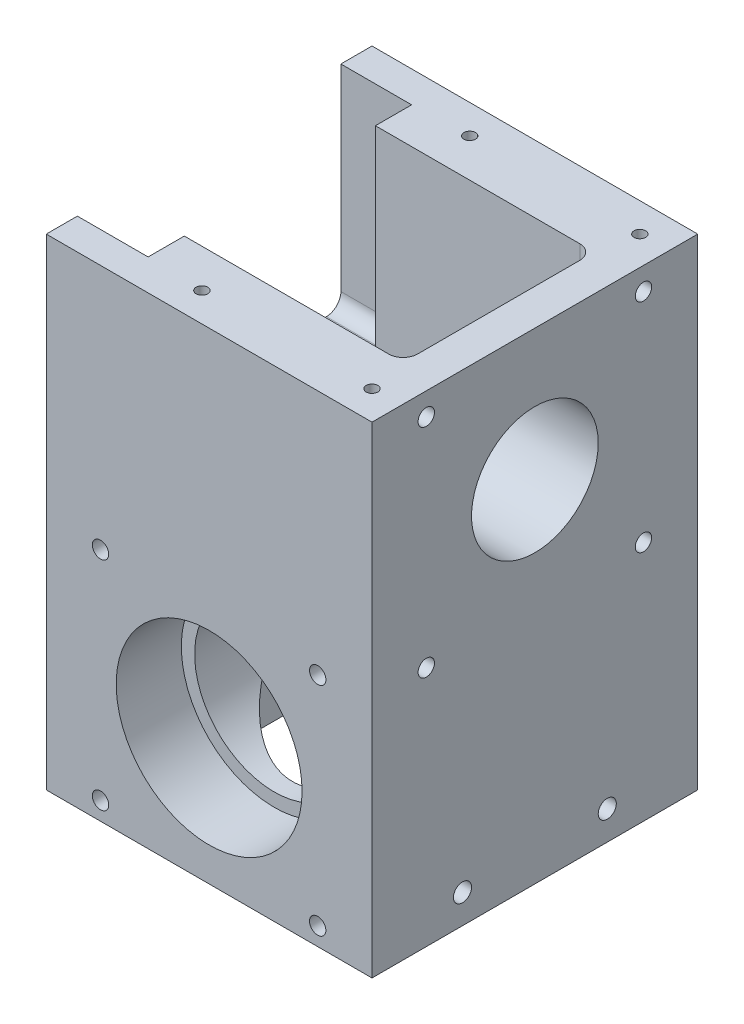
from build123d import *

# Parameters (mm, degrees)
SKETCH1_W                  = 45
SKETCH1_H                  = 45
BOSS_EXTRUDE1_DEPTH        = 30
BOSS_EXTRUDE1_DEPTH_BACK   = 35
F_22_0_22_DIAMETER_HOLE1_D = 22
F_22_0_22_DIAMETER_HOLE2_D = 22
SKETCH7_R                  = 12.8397
CUT_EXTRUDE1_DEPTH         = 9
CUT_EXTRUDE2_DEPTH         = 13.2
CUT_EXTRUDE3_REACH         = 29.667
SKETCH9_W                  = 26.4
SKETCH9_H                  = 36
FILLET1_R                  = 2
CUT_EXTRUDE6_REACH         = 29.667
CUT_EXTRUDE4_DEPTH         = 4.499464
CUT_EXTRUDE5_DEPTH         = 9.772078
CUT_EXTRUDE7_DEPTH         = 15
BOSS_EXTRUDE2_DEPTH        = 1.5
M2_TAPPED_HOLE1_D          = 1.6
M2_TAPPED_HOLE1_DEPTH      = 3.2
M2_TAPPED_HOLE1_TIP        = 0.480688495
M2_TAPPED_HOLE2_D          = 1.6
M2_TAPPED_HOLE2_DEPTH      = 5.2
M2_TAPPED_HOLE2_TIP        = 0.480688495
M2_TAPPED_HOLE3_D          = 1.6
M2_TAPPED_HOLE3_DEPTH      = 5.2
M2_TAPPED_HOLE3_TIP        = 0.480688495
M3_TAPPED_HOLE1_D          = 2.5
M3_TAPPED_HOLE2_D          = 2.5
M3_TAPPED_HOLE2_DEPTH      = 7.5
M3_TAPPED_HOLE2_TIP        = 0.751075774
M2_TAPPED_HOLE4_D          = 1.6
M2_TAPPED_HOLE4_DEPTH      = 5.2
M2_TAPPED_HOLE4_TIP        = 0.480688495
CUT_EXTRUDE8_REACH         = 47
SKETCH30_R                 = 8.75
F_4_40_TAPPED_HOLE1_D      = 2.2606
F_4_40_TAPPED_HOLE1_DEPTH  = 4.2
F_4_40_TAPPED_HOLE1_TIP    = 0.679152758
F_4_40_TAPPED_HOLE2_D      = 2.2606
F_4_40_TAPPED_HOLE2_DEPTH  = 5.18
F_4_40_TAPPED_HOLE2_TIP    = 0.679152758


with BuildPart() as part:
    # Sketch1 → Boss-Extrude1 (new body, two sides)
    with BuildSketch(Plane(origin=(0, 0, 0), x_dir=(1, 0, 0), z_dir=(0, 1, 0))) as boss_extrude1_sk:
        Rectangle(SKETCH1_W, SKETCH1_H)
    extrude(amount=BOSS_EXTRUDE1_DEPTH)
    extrude(boss_extrude1_sk.sketch, amount=-BOSS_EXTRUDE1_DEPTH_BACK)

    # Ø22.0 (22) Diameter Hole1 (through all)
    with Locations(Plane(origin=(0, 30, 0), x_dir=(1, 0, 0), z_dir=(0, 1, 0))):
        with Locations((0, 0)):
            Hole(F_22_0_22_DIAMETER_HOLE1_D / 2)

    # Ø22.0 (22) Diameter Hole2 (through all)
    with Locations(Plane.XY.offset(22.5)):
        with Locations((0, -17.5)):
            Hole(F_22_0_22_DIAMETER_HOLE2_D / 2)

    # Sketch7 → Cut-Extrude1 (cut)
    with BuildSketch(Plane.XY.offset(22.5)):
        with Locations((0, -17.5)):
            Circle(SKETCH7_R)
    extrude(amount=-CUT_EXTRUDE1_DEPTH, mode=Mode.SUBTRACT)

    # Sketch8 → Cut-Extrude2 (cut, symmetric)
    with BuildSketch(Plane.XY):
        Polygon((-12.727922061, 2.272077939), (-11.914749263, 1.45890514), (13.54109486, 26.914749263), (12.727922061, 27.727922061), align=None)
    extrude(amount=CUT_EXTRUDE2_DEPTH, both=True, mode=Mode.SUBTRACT)

    # Sketch9 → Cut-Extrude3 (cut, up to next)
    with BuildSketch(Plane(origin=(-6.686827202, 6.686827202, 0), x_dir=(0, 0, 1), z_dir=(-0.707106781, 0.707106781, 0)), mode=Mode.PRIVATE) as cut_extrude3_sk1:
        with Locations((0, 10.606601718)):
            Rectangle(SKETCH9_W, SKETCH9_H)
    cut_extrude3_tool1 = extrude(cut_extrude3_sk1.sketch, amount=CUT_EXTRUDE3_REACH, mode=Mode.PRIVATE) & part.part
    add(cut_extrude3_tool1.solids().sort_by_distance((0.813173, 14.186827, 0))[0], mode=Mode.SUBTRACT)

    # Fillet1
    fillet1_edges = [part.edges().sort_by_distance(p)[0] for p in [
        (11.998469491, 28.457374631, -13.2),
        (-17.207374631, 6.751530509, -13.2),
        (-17.207374631, 6.751530509, 13.2),
        (11.998469491, 28.457374631, 13.2),
    ]]
    fillet(fillet1_edges, radius=FILLET1_R)

    # Sketch12 → Cut-Extrude6 (cut, up to next)
    with BuildSketch(Plane(origin=(-6.686827202, 6.686827202, 0), x_dir=(0, 0, 1), z_dir=(-0.707106781, 0.707106781, 0)), mode=Mode.PRIVATE) as cut_extrude6_sk1:
        with BuildLine():
            Line((-9.2, -5.393398282), (-9.2, -7.393398282))
            ThreePointArc((-9.2, -7.393398282), (-11.2, -9.393398282), (-13.2, -7.393398282))
            Line((-13.2, -7.393398282), (-13.2, -5.393398282))
            ThreePointArc((-13.2, -5.393398282), (-11.2, -3.393398282), (-9.2, -5.393398282))
        make_face()
    cut_extrude6_tool1 = extrude(cut_extrude6_sk1.sketch, amount=CUT_EXTRUDE6_REACH, mode=Mode.PRIVATE) & part.part
    add(cut_extrude6_tool1.solids().sort_by_distance((-11.207642, 2.166012, -11.2))[0], mode=Mode.SUBTRACT)
    # Sketch12 → Cut-Extrude6 (cut, up to next)
    with BuildSketch(Plane(origin=(-6.686827202, 6.686827202, 0), x_dir=(0, 0, 1), z_dir=(-0.707106781, 0.707106781, 0)), mode=Mode.PRIVATE) as cut_extrude6_sk2:
        with BuildLine():
            Line((13.2, -5.393398282), (13.2, -7.393398282))
            ThreePointArc((13.2, -7.393398282), (11.2, -9.393398282), (9.2, -7.393398282))
            Line((9.2, -7.393398282), (9.2, -5.393398282))
            ThreePointArc((9.2, -5.393398282), (11.2, -3.393398282), (13.2, -5.393398282))
        make_face()
    cut_extrude6_tool2 = extrude(cut_extrude6_sk2.sketch, amount=CUT_EXTRUDE6_REACH, mode=Mode.PRIVATE) & part.part
    add(cut_extrude6_tool2.solids().sort_by_distance((-11.207642, 2.166012, 11.2))[0], mode=Mode.SUBTRACT)

    # Sketch10 → Cut-Extrude4 (cut)
    with BuildSketch(Plane(origin=(0, 30, 0), x_dir=(1, 0, 0), z_dir=(0, 1, 0))):
        with BuildLine():
            Line((7.627416998, 13.2), (15.5, 13.2))
            ThreePointArc((15.5, 13.2), (16.914213562, 12.614213562), (17.5, 11.2))
            Line((17.5, 11.2), (17.5, -11.2))
            ThreePointArc((17.5, -11.2), (16.914213562, -12.614213562), (15.5, -13.2))
            Line((15.5, -13.2), (7.627416998, -13.2))
            Line((7.627416998, -13.2), (7.627416998, 13.2))
        make_face()
    extrude(amount=-CUT_EXTRUDE4_DEPTH, mode=Mode.SUBTRACT)

    # Sketch11 → Cut-Extrude5 (cut)
    with BuildSketch(Plane.ZY.offset(22.5)):
        with BuildLine():
            Line((-18.2, 30), (18.2, 30))
            Line((18.2, 30), (18.2, 4.272077939))
            ThreePointArc((18.2, 4.272077939), (17.614213562, 2.857864376), (16.2, 2.272077939))
            Line((16.2, 2.272077939), (-16.2, 2.272077939))
            ThreePointArc((-16.2, 2.272077939), (-17.614213562, 2.857864376), (-18.2, 4.272077939))
            Line((-18.2, 4.272077939), (-18.2, 30))
        make_face()
    extrude(amount=-CUT_EXTRUDE5_DEPTH, mode=Mode.SUBTRACT)

    # Sketch13 → Cut-Extrude7 (cut, symmetric)
    with BuildSketch(Plane(origin=(0, 0, 0), x_dir=(0, 0, -1), z_dir=(1, 0, 0))):
        Polygon((-17.5, -35), (22.5, 5), (22.5, -35), align=None)
    extrude(amount=CUT_EXTRUDE7_DEPTH, both=True, mode=Mode.SUBTRACT)

    # Sketch18 → Boss-Extrude2 (add)
    with BuildSketch(Plane(origin=(0, 30, 0), x_dir=(1, 0, 0), z_dir=(0, 1, 0))):
        with BuildLine():
            Line((-12.727922061, -13.2), (-12.727922061, -18.2))
            Line((-12.727922061, -18.2), (-22.5, -18.2))
            Line((-22.5, -18.2), (-22.5, -22.5))
            Line((-22.5, -22.5), (22.5, -22.5))
            Line((22.5, -22.5), (22.5, 22.5))
            Line((22.5, 22.5), (-22.5, 22.5))
            Line((-22.5, 22.5), (-22.5, 18.2))
            Line((-22.5, 18.2), (-12.727922061, 18.2))
            Line((-12.727922061, 18.2), (-12.727922061, 13.2))
            Line((-12.727922061, 13.2), (15.5, 13.2))
            ThreePointArc((15.5, 13.2), (16.914213562, 12.614213562), (17.5, 11.2))
            Line((17.5, 11.2), (17.5, -11.2))
            ThreePointArc((17.5, -11.2), (16.914213562, -12.614213562), (15.5, -13.2))
            Line((15.5, -13.2), (-12.727922061, -13.2))
        make_face()
    extrude(amount=BOSS_EXTRUDE2_DEPTH)

    # M2 Tapped Hole1
    with Locations(Plane(origin=(0, -8.75, -8.75), x_dir=(-1, 0, 0), z_dir=(0, -0.707106781, -0.707106781))):
        with Locations((11.75, -28.123106012), (11.75, 10.876893988), (-11.75, 10.876893988), (-11.75, -28.123106012)):
            Hole(M2_TAPPED_HOLE1_D / 2, depth=M2_TAPPED_HOLE1_DEPTH)
            with Locations((0, 0, -(M2_TAPPED_HOLE1_DEPTH + M2_TAPPED_HOLE1_TIP / 2))):  # 118° drill point
                Cone(0, M2_TAPPED_HOLE1_D / 2, M2_TAPPED_HOLE1_TIP, mode=Mode.SUBTRACT)

    # M2 Tapped Hole2
    with Locations(Plane(origin=(0, 25.500535701, 0), x_dir=(1, 0, 0), z_dir=(0, 1, 0))):
        with Locations((14.5, 7), (14.5, -7)):
            Hole(M2_TAPPED_HOLE2_D / 2, depth=M2_TAPPED_HOLE2_DEPTH)
            with Locations((0, 0, -(M2_TAPPED_HOLE2_DEPTH + M2_TAPPED_HOLE2_TIP / 2))):  # 118° drill point
                Cone(0, M2_TAPPED_HOLE2_D / 2, M2_TAPPED_HOLE2_TIP, mode=Mode.SUBTRACT)

    # M2 Tapped Hole3
    with Locations(Plane(origin=(0, 31.5, 0), x_dir=(1, 0, 0), z_dir=(0, 1, 0))):
        with Locations((-5, 18.5), (18.5, 18.5), (-5, -18.5), (18.5, -18.5)):
            Hole(M2_TAPPED_HOLE3_D / 2, depth=M2_TAPPED_HOLE3_DEPTH)
            with Locations((0, 0, -(M2_TAPPED_HOLE3_DEPTH + M2_TAPPED_HOLE3_TIP / 2))):  # 118° drill point
                Cone(0, M2_TAPPED_HOLE3_D / 2, M2_TAPPED_HOLE3_TIP, mode=Mode.SUBTRACT)

    # M3 Tapped Hole1 (through all)
    with Locations(Plane.ZY.offset(22.5)):
        with Locations((-10, -31), (10, -31)):
            Hole(M3_TAPPED_HOLE1_D / 2)

    # M3 Tapped Hole2
    with Locations(Plane(origin=(0, -35, 0), x_dir=(-1, 0, 0), z_dir=(0, -1, 0))):
        with Locations((-19, -19), (19, 19), (19, -19), (-19, 19)):
            Hole(M3_TAPPED_HOLE2_D / 2, depth=M3_TAPPED_HOLE2_DEPTH)
            with Locations((0, 0, -(M3_TAPPED_HOLE2_DEPTH + M3_TAPPED_HOLE2_TIP / 2))):  # 118° drill point
                Cone(0, M3_TAPPED_HOLE2_D / 2, M3_TAPPED_HOLE2_TIP, mode=Mode.SUBTRACT)

    # M2 Tapped Hole4
    with Locations(Plane.ZY.offset(12.727922061)):
        with Locations((-14.7, 24), (14.7, 24)):
            Hole(M2_TAPPED_HOLE4_D / 2, depth=M2_TAPPED_HOLE4_DEPTH)
            with Locations((0, 0, -(M2_TAPPED_HOLE4_DEPTH + M2_TAPPED_HOLE4_TIP / 2))):  # 118° drill point
                Cone(0, M2_TAPPED_HOLE4_D / 2, M2_TAPPED_HOLE4_TIP, mode=Mode.SUBTRACT)

    # Sketch30 → Cut-Extrude8 (cut, up to next)
    with BuildSketch(Plane(origin=(22.5, 0, 0), x_dir=(0, 0, -1), z_dir=(1, 0, 0)), mode=Mode.PRIVATE) as cut_extrude8_sk1:
        with Locations((0, 13.373654403)):
            Circle(SKETCH30_R)
    cut_extrude8_tool1 = extrude(cut_extrude8_sk1.sketch, amount=-CUT_EXTRUDE8_REACH, mode=Mode.PRIVATE) & part.part
    add(cut_extrude8_tool1.solids().sort_by_distance((22.5, 13.373654, 0))[0], mode=Mode.SUBTRACT)

    # #4-40 Tapped Hole1
    with Locations(Plane(origin=(22.5, 0, 0), x_dir=(0, 0, -1), z_dir=(1, 0, 0))):
        with Locations((-15, 28.373654403), (-15, -1.626345597), (15, -1.626345597), (15, 28.373654403)):
            Hole(F_4_40_TAPPED_HOLE1_D / 2, depth=F_4_40_TAPPED_HOLE1_DEPTH)
            with Locations((0, 0, -(F_4_40_TAPPED_HOLE1_DEPTH + F_4_40_TAPPED_HOLE1_TIP / 2))):  # 118° drill point
                Cone(0, F_4_40_TAPPED_HOLE1_D / 2, F_4_40_TAPPED_HOLE1_TIP, mode=Mode.SUBTRACT)

    # #4-40 Tapped Hole2
    with Locations(Plane.XY.offset(22.5)):
        with Locations((-15, -2.5), (15, -2.5), (-15, -32.5), (15, -32.5)):
            Hole(F_4_40_TAPPED_HOLE2_D / 2, depth=F_4_40_TAPPED_HOLE2_DEPTH)
            with Locations((0, 0, -(F_4_40_TAPPED_HOLE2_DEPTH + F_4_40_TAPPED_HOLE2_TIP / 2))):  # 118° drill point
                Cone(0, F_4_40_TAPPED_HOLE2_D / 2, F_4_40_TAPPED_HOLE2_TIP, mode=Mode.SUBTRACT)


solid = part.part
